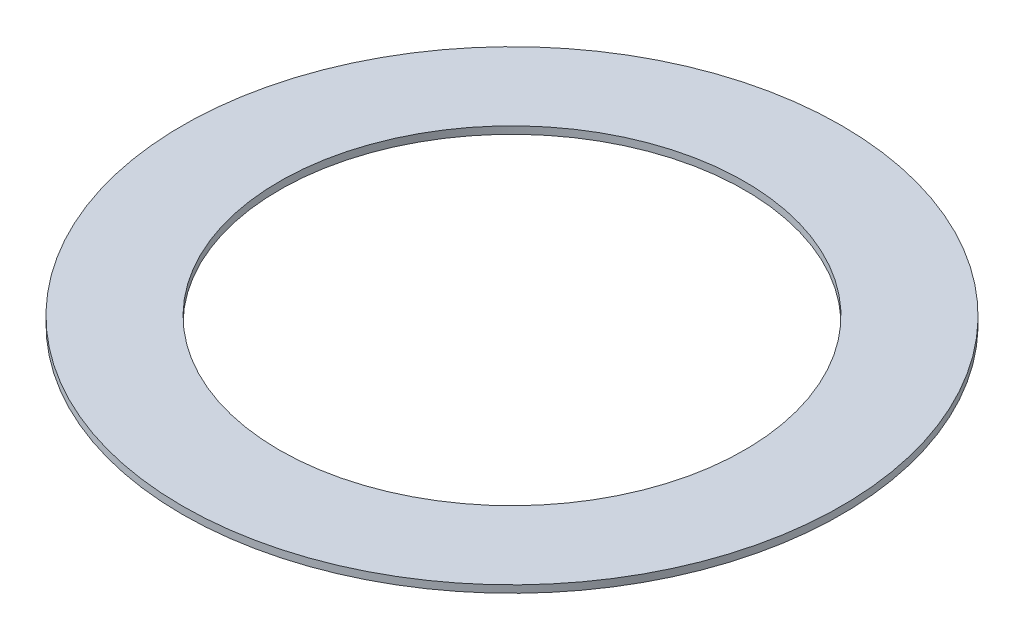
from build123d import *

# Parameters (mm, degrees)
SKETCH1_R           = 107.95
SKETCH1_R_2         = 76.2
BOSS_EXTRUDE1_DEPTH = 2.4


with BuildPart() as part:
    # Sketch1 → Boss-Extrude1 (new body)
    with BuildSketch(Plane(origin=(0, 0, 0), x_dir=(1, 0, 0), z_dir=(0, 1, 0))):
        Circle(SKETCH1_R)
        Circle(SKETCH1_R_2, mode=Mode.SUBTRACT)
    extrude(amount=BOSS_EXTRUDE1_DEPTH)


solid = part.part
